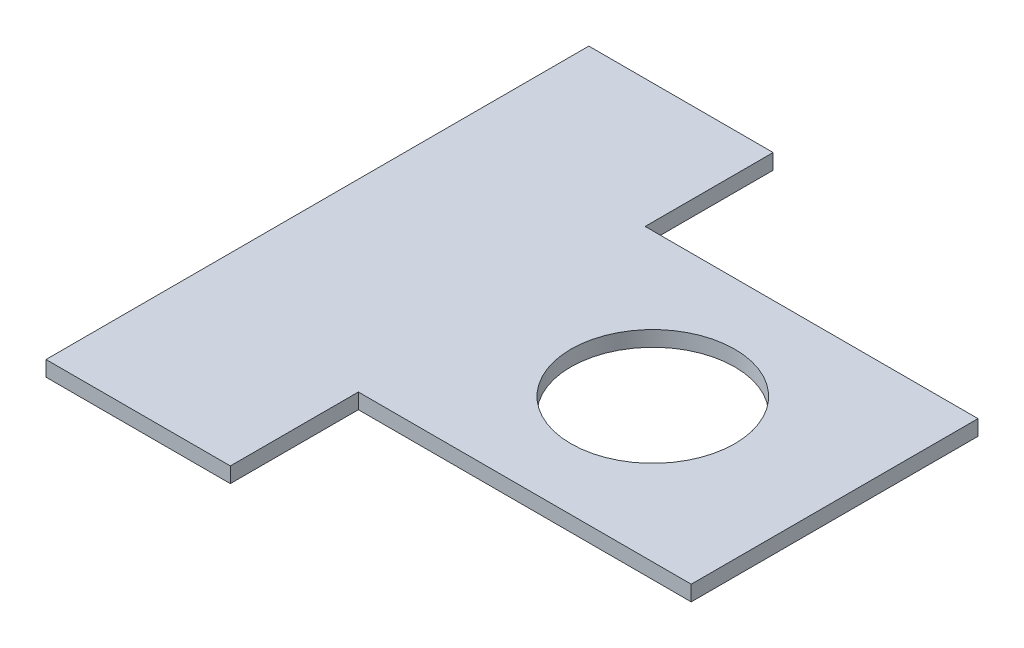
from build123d import *

# Parameters (mm, degrees)
SKETCH1_R           = 16
BOSS_EXTRUDE1_DEPTH = 3


with BuildPart() as part:
    # Sketch1 → Boss-Extrude1 (new body)
    with BuildSketch(Plane(origin=(0, 0, 0), x_dir=(1, 0, 0), z_dir=(0, 1, 0))):
        Polygon((0, -53), (0, 53), (36, 53), (36, 28), (101, 28), (101, -28), (36, -28), (36, -53), align=None)
        with Locations((65.5, 0)):
            Circle(SKETCH1_R, mode=Mode.SUBTRACT)
    extrude(amount=BOSS_EXTRUDE1_DEPTH)


solid = part.part
